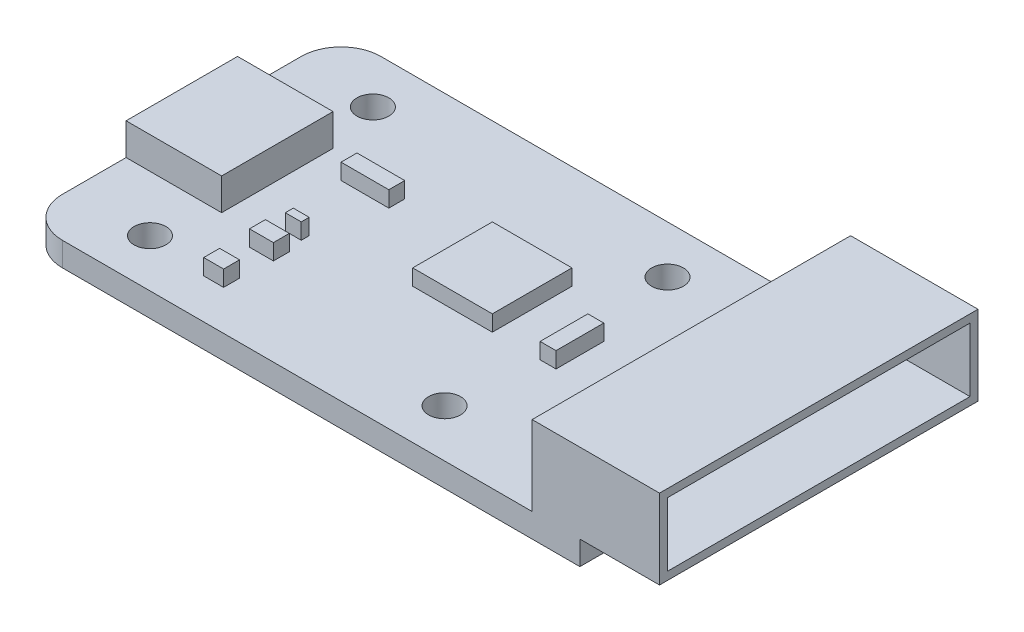
from build123d import *

# Parameters (mm, degrees)
SKETCH1_W           = 35
SKETCH1_H           = 20
BOSS_EXTRUDE1_DEPTH = 1.5
FILLET1_R           = 2.5
SKETCH2_R           = 1
CUT_EXTRUDE1_DEPTH  = 1.5
SKETCH3_W           = 6
SKETCH3_H           = 7
BOSS_EXTRUDE2_DEPTH = 2
SKETCH4_W           = 6.5
SKETCH4_H           = 1.5
CUT_EXTRUDE2_DEPTH  = 5.5
SKETCH5_W           = 8
SKETCH5_H           = 20
BOSS_EXTRUDE3_DEPTH = 5
SKETCH6_W           = 19
SKETCH6_H           = 4
CUT_EXTRUDE3_DEPTH  = 7
SKETCH7_W           = 5
SKETCH7_H           = 5
BOSS_EXTRUDE4_DEPTH = 1
SKETCH8_W           = 1.25
SKETCH8_H           = 1
SKETCH8_W_2         = 1.5
SKETCH8_W_3         = 1
SKETCH8_H_2         = 0.5
SKETCH8_W_4         = 3
SKETCH8_H_3         = 3
BOSS_EXTRUDE5_DEPTH = 1


with BuildPart() as part:
    # Sketch1 → Boss-Extrude1 (new body)
    with BuildSketch(Plane(origin=(0, 0, 0), x_dir=(1, 0, 0), z_dir=(0, 1, 0))):
        Rectangle(SKETCH1_W, SKETCH1_H)
    extrude(amount=BOSS_EXTRUDE1_DEPTH)

    # Fillet1
    fillet1_edges = [part.edges().sort_by_distance(p)[0] for p in [
        (-17.5, 0.75, 10),
        (-17.5, 0.75, -10),
    ]]
    fillet(fillet1_edges, radius=FILLET1_R)

    # Sketch2 → Cut-Extrude1 (cut)
    with BuildSketch(Plane(origin=(0, 1.5, 0), x_dir=(1, 0, 0), z_dir=(0, 1, 0))):
        with Locations((-12.5, 7)):
            Circle(SKETCH2_R)
        with Locations((6, 7)):
            Circle(SKETCH2_R)
        with Locations((6, -7)):
            Circle(SKETCH2_R)
        with Locations((-12.5, -7)):
            Circle(SKETCH2_R)
    extrude(amount=-CUT_EXTRUDE1_DEPTH, mode=Mode.SUBTRACT)

    # Sketch3 → Boss-Extrude2 (add)
    with BuildSketch(Plane(origin=(0, 1.5, 0), x_dir=(1, 0, 0), z_dir=(0, 1, 0))):
        with Locations((-14.5, 0)):
            Rectangle(SKETCH3_W, SKETCH3_H)
    extrude(amount=BOSS_EXTRUDE2_DEPTH)

    # Sketch4 → Cut-Extrude2 (cut)
    with BuildSketch(Plane.ZY.offset(17.5)):
        with Locations((0, 2.5)):
            Rectangle(SKETCH4_W, SKETCH4_H)
    extrude(amount=-CUT_EXTRUDE2_DEPTH, mode=Mode.SUBTRACT)

    # Sketch5 → Boss-Extrude3 (add)
    with BuildSketch(Plane(origin=(0, 1.5, 0), x_dir=(1, 0, 0), z_dir=(0, 1, 0))):
        with Locations((18.5, 0)):
            Rectangle(SKETCH5_W, SKETCH5_H)
    extrude(amount=BOSS_EXTRUDE3_DEPTH)

    # Sketch6 → Cut-Extrude3 (cut)
    with BuildSketch(Plane(origin=(22.5, 0, 0), x_dir=(0, 0, -1), z_dir=(1, 0, 0))):
        with Locations((0, 4)):
            Rectangle(SKETCH6_W, SKETCH6_H)
    extrude(amount=-CUT_EXTRUDE3_DEPTH, mode=Mode.SUBTRACT)

    # Sketch7 → Boss-Extrude4 (add)
    with BuildSketch(Plane(origin=(0, 1.5, 0), x_dir=(1, 0, 0), z_dir=(0, 1, 0))):
        with Locations((1, 1)):
            Rectangle(SKETCH7_W, SKETCH7_H)
    extrude(amount=BOSS_EXTRUDE4_DEPTH)

    # Sketch8 → Boss-Extrude5 (add)
    with BuildSketch(Plane(origin=(0, 1.5, 0), x_dir=(1, 0, 0), z_dir=(0, 1, 0))):
        with Locations((-8, -7)):
            Rectangle(SKETCH8_W, SKETCH8_H)
        with Locations((-8, -4)):
            Rectangle(SKETCH8_W_2, SKETCH8_H)
        with Locations((-8, -2.25)):
            Rectangle(SKETCH8_W_3, SKETCH8_H_2)
        with Locations((-8, 2.5)):
            Rectangle(SKETCH8_W_4, SKETCH8_H)
        with Locations((7, 0)):
            Rectangle(SKETCH8_W_3, SKETCH8_H_3)
    extrude(amount=BOSS_EXTRUDE5_DEPTH)


solid = part.part
